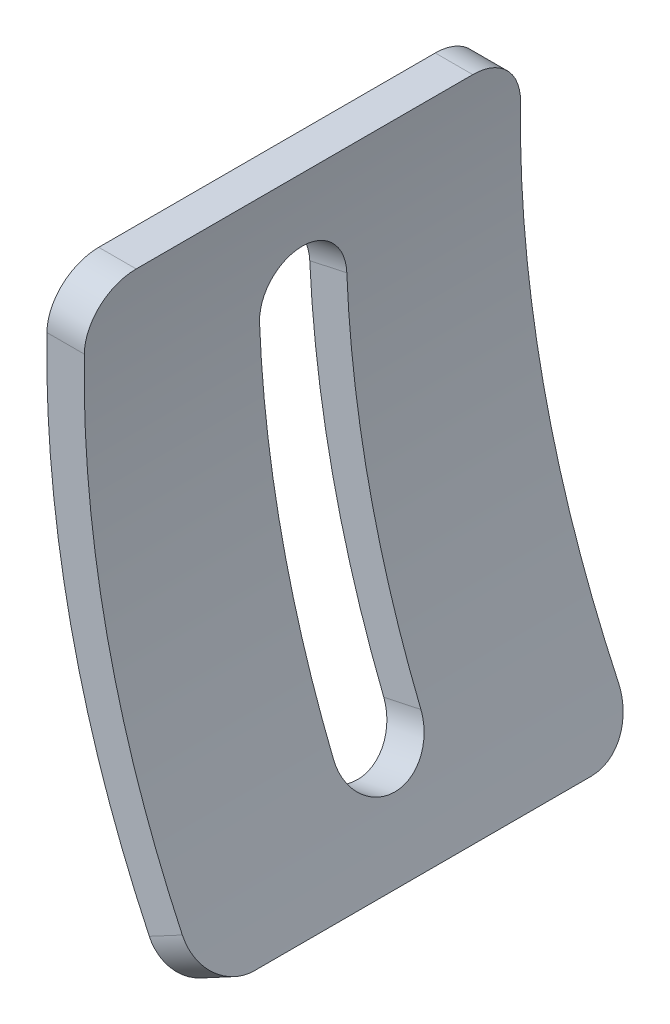
from build123d import *

# Parameters (mm, degrees)
EXTRUSION1_DEPTH        = 17.5
CONG_1_R                = 4
ENL_V_MAT_EXTRU_1_DEPTH = 35


with BuildPart() as part:
    # Esquisse1 → Extrusion1 (new body, symmetric)
    with BuildSketch(Plane.XY):
        with BuildLine():
            Line((0, 0), (-3.006199407, 0))
            ThreePointArc((-3.006199407, 0), (-1.239978733, -23.393785135), (6.853974171, -45.413699867))
            Line((6.853974171, -45.413699867), (9.5, -44))
            ThreePointArc((9.5, -44), (1.671662982, -22.664640947), (0, 0))
        make_face()
    extrude(amount=EXTRUSION1_DEPTH, both=True)

    # Congé1
    cong_1_edges = [part.edges().sort_by_distance(p)[0] for p in [
        (-1.503099703, 0, 17.5),
        (-1.503099703, 0, -17.5),
        (8.176987086, -44.706849934, -17.5),
        (8.176987086, -44.706849934, 17.5),
    ]]
    fillet(cong_1_edges, radius=CONG_1_R)

    # Esquisse2 → Enlèv. mat.-Extru.1 (cut)
    with BuildSketch(Plane(origin=(0, 0, 0), x_dir=(0, 0, 1), z_dir=(-0.977476134, -0.211045984, 0))):
        with BuildLine():
            Line((-3.5, -36.601432597), (-3.5, -8.601432597))
            ThreePointArc((-3.5, -8.601432597), (0, -5.101432597), (3.5, -8.601432597))
            Line((3.5, -8.601432597), (3.5, -36.601432597))
            ThreePointArc((3.5, -36.601432597), (0, -40.101432597), (-3.5, -36.601432597))
        make_face()
    extrude(amount=ENL_V_MAT_EXTRU_1_DEPTH, mode=Mode.SUBTRACT)


solid = part.part
